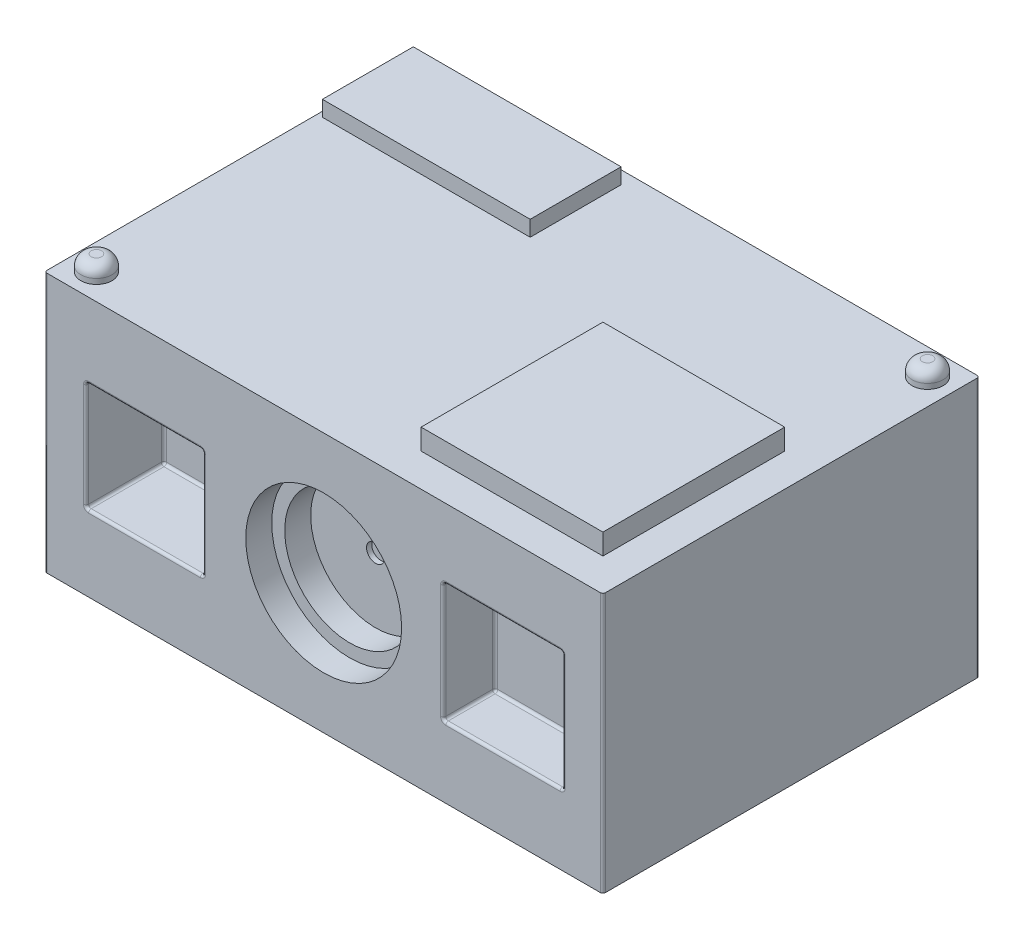
from build123d import *

# Parameters (mm, degrees)
SKETCH_1_W          = 21.5
SKETCH_1_H          = 14.5
EXTRUDE_1_DEPTH     = 10
SKETCH_2_W          = 4.5
SKETCH_2_H          = 4.2
CUT_EXTRUDE_1_DEPTH = 3
SKETCH_2_3_W        = 4.6
SKETCH_2_3_H        = 4.6
SKETCH_2_3_R        = 2.5
CUT_EXTRUDE_2_DEPTH = 2
SKETCH_2_4_R        = 3
SKETCH_2_4_R_2      = 2.5
CUT_EXTRUDE_3_DEPTH = 1
SKETCH_3_W          = 7
SKETCH_3_H          = 7
EXTRUDE_2_DEPTH     = 0.8
SKETCH_4_R          = 0.6
SKETCH_4_W          = 8
SKETCH_4_H          = 3.5
EXTRUDE_3_DEPTH     = 0.6
FILLET_1_R          = 0.4
SKETCH_5_R          = 0.35
CUT_EXTRUDE_4_DEPTH = 0.2
FILLET_2_R          = 0.1


with BuildPart() as part:
    # 草图1 → 凸台-拉伸1 (new body)
    with BuildSketch(Plane(origin=(0, 0, 0), x_dir=(1, 0, 0), z_dir=(0, 1, 0))):
        Rectangle(SKETCH_1_W, SKETCH_1_H)
    extrude(amount=EXTRUDE_1_DEPTH)

    # 草图2 → 切除-拉伸1 (cut)
    with BuildSketch(Plane.XY.offset(7.25)):
        with Locations((-6.9, 5)):
            Rectangle(SKETCH_2_W, SKETCH_2_H)
    extrude(amount=-CUT_EXTRUDE_1_DEPTH, mode=Mode.SUBTRACT)

    # 草图2<3> → 切除-拉伸2 (cut)
    with BuildSketch(Plane.XY.offset(7.25)):
        with Locations((6.9, 5)):
            Rectangle(SKETCH_2_3_W, SKETCH_2_3_H)
        with Locations((0, 5)):
            Circle(SKETCH_2_3_R)
    extrude(amount=-CUT_EXTRUDE_2_DEPTH, mode=Mode.SUBTRACT)

    # 草图2<4> → 切除-拉伸3 (cut)
    with BuildSketch(Plane.XY.offset(7.25)):
        with Locations((0, 5)):
            Circle(SKETCH_2_4_R)
        with Locations((0, 5)):
            Circle(SKETCH_2_4_R_2, mode=Mode.SUBTRACT)
    extrude(amount=-CUT_EXTRUDE_3_DEPTH, mode=Mode.SUBTRACT)

    # 草图3 → 凸台-拉伸2 (add)
    with BuildSketch(Plane(origin=(0, 10, 0), x_dir=(1, 0, 0), z_dir=(0, 1, 0))):
        with Locations((5.98, -2.48)):
            Rectangle(SKETCH_3_W, SKETCH_3_H)
    extrude(amount=EXTRUDE_2_DEPTH)

    # 草图4 → 凸台-拉伸3 (add)
    with BuildSketch(Plane(origin=(0, 10, 0), x_dir=(1, 0, 0), z_dir=(0, 1, 0))):
        with Locations((-9.75, -6.25)):
            Circle(SKETCH_4_R)
        with Locations((9.75, 6.25)):
            Circle(SKETCH_4_R)
        with Locations((-6.55, 5)):
            Rectangle(SKETCH_4_W, SKETCH_4_H)
    extrude(amount=EXTRUDE_3_DEPTH)

    # 圆角1
    fillet_1_edges = [part.edges().sort_by_distance(p)[0] for p in [
        (9.15, 10.6, -6.25),
        (-10.35, 10.6, 6.25),
    ]]
    fillet(fillet_1_edges, radius=FILLET_1_R)

    # 草图5 → 切除-拉伸4 (cut)
    with BuildSketch(Plane.XY.offset(5.25)):
        with Locations((0, 5)):
            Circle(SKETCH_5_R)
    extrude(amount=-CUT_EXTRUDE_4_DEPTH, mode=Mode.SUBTRACT)

    # 圆角2
    fillet_2_edges = [part.edges().sort_by_distance(p)[0] for p in [
        (-6.9, 2.9, 7.25),
        (6.9, 2.7, 7.25),
        (-9.15, 5, 7.25),
        (-4.65, 5, 7.25),
        (4.6, 5, 7.25),
        (9.2, 5, 7.25),
        (4.6, 5, 5.25),
        (6.9, 7.3, 5.25),
        (9.2, 5, 5.25),
        (6.9, 2.7, 5.25),
        (-6.9, 2.9, 4.25),
        (-9.15, 5, 4.25),
        (-6.9, 7.1, 4.25),
        (-4.65, 5, 4.25),
        (-6.9, 7.1, 7.25),
        (6.9, 7.3, 7.25),
        (9.2, 2.7, 6.25),
        (4.6, 2.7, 6.25),
        (9.2, 7.3, 6.25),
        (4.6, 7.3, 6.25),
        (-4.65, 2.9, 5.75),
        (-9.15, 2.9, 5.75),
        (-9.15, 7.1, 5.75),
        (-4.65, 7.1, 5.75),
        (-10.75, 5, 7.25),
        (-10.75, 5, -7.25),
        (10.75, 5, -7.25),
        (10.75, 5, 7.25),
    ]]
    fillet(fillet_2_edges, radius=FILLET_2_R)


solid = part.part
